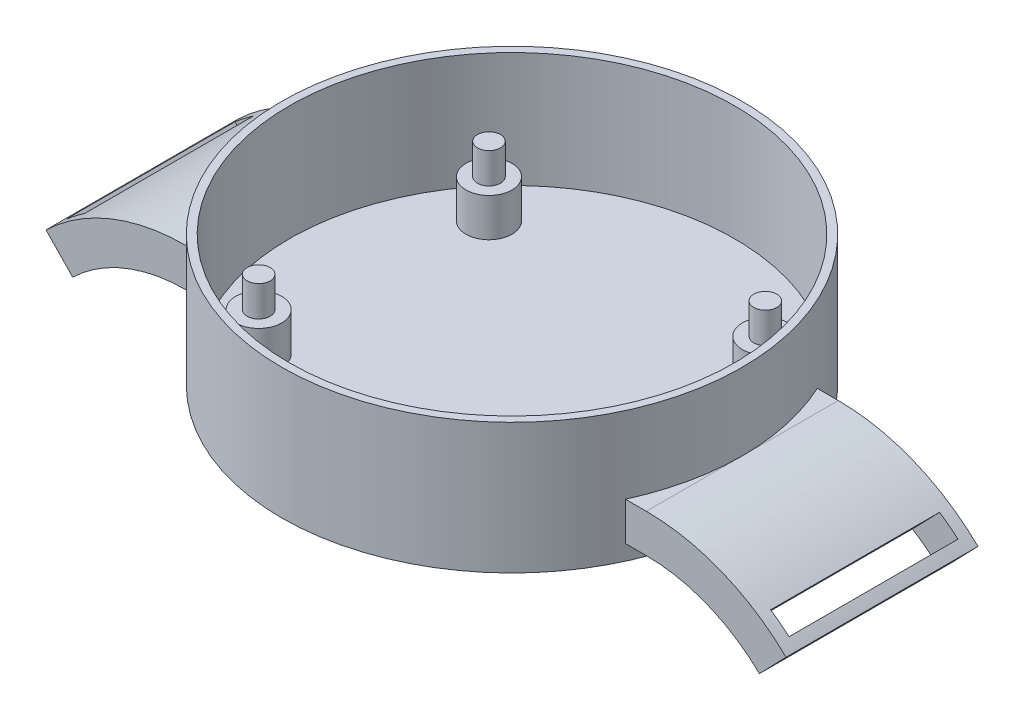
from build123d import *

# Parameters (mm, degrees)
SKETCH1_R                = 30
BOSS_EXTRUDE1_DEPTH      = 17
SKETCH2_R                = 29
CUT_EXTRUDE1_DEPTH       = 15
SKETCH3_R                = 3
BOSS_EXTRUDE5_DEPTH      = 5
SKETCH4_R                = 1.5
BOSS_EXTRUDE6_DEPTH      = 4
BOSS_EXTRUDE7_REACH      = 71.203
BOSS_EXTRUDE7_END_RADIUS = 30
SKETCH6_W                = 25
SKETCH6_H                = 5
SKETCH9_W                = 25
SKETCH9_H                = 5
SKETCH10_W               = 3
SKETCH10_H               = 22
CUT_EXTRUDE2_DEPTH       = 10
CIRPATTERN1_COUNT        = 2


with BuildPart() as part:
    # Sketch1 → Boss-Extrude1 (new body)
    with BuildSketch(Plane(origin=(0, 0, 0), x_dir=(1, 0, 0), z_dir=(0, 1, 0))):
        with Locations(Location((0, 0, 0), (0, 0, 270))):
            Circle(SKETCH1_R)
    extrude(amount=BOSS_EXTRUDE1_DEPTH)

    # Sketch2 → Cut-Extrude1 (cut)
    with BuildSketch(Plane(origin=(0, 17, 0), x_dir=(1, 0, 0), z_dir=(0, 1, 0))):
        with Locations(Location((0, 0, 0), (0, 0, 270))):
            Circle(SKETCH2_R)
    extrude(amount=-CUT_EXTRUDE1_DEPTH, mode=Mode.SUBTRACT)

    # Sketch3 → Boss-Extrude5 (add)
    with BuildSketch(Plane(origin=(0, 2, 0), x_dir=(1, 0, 0), z_dir=(0, 1, 0))):
        with Locations(Location((-18, 15, 0), (0, 0, 270))):
            Circle(SKETCH3_R)
        with Locations(Location((-18, -15, 0), (0, 0, 270))):
            Circle(SKETCH3_R)
        with Locations(Location((18, -15, 0), (0, 0, 270))):
            Circle(SKETCH3_R)
        with Locations(Location((18, 15, 0), (0, 0, 270))):
            Circle(SKETCH3_R)
    extrude(amount=BOSS_EXTRUDE5_DEPTH)

    # Sketch4 → Boss-Extrude6 (add)
    with BuildSketch(Plane(origin=(0, 7, 0), x_dir=(1, 0, 0), z_dir=(0, 1, 0))):
        with Locations(Location((-18, 15, 0), (0, 0, 270))):
            Circle(SKETCH4_R)
        with Locations(Location((-18, -15, 0), (0, 0, 270))):
            Circle(SKETCH4_R)
        with Locations(Location((18, 15, 0), (0, 0, 270))):
            Circle(SKETCH4_R)
        with Locations(Location((18, -15, 0), (0, 0, 270))):
            Circle(SKETCH4_R)
    extrude(amount=BOSS_EXTRUDE6_DEPTH)

    # Boss-Extrude7: up to this cylinder (the profile starts outside it)
    boss_extrude7_end = Plane(origin=(0, 4.5, 0), z_dir=(0, -1, 0)) * Cylinder(BOSS_EXTRUDE7_END_RADIUS, 203.406, mode=Mode.PRIVATE)
    # Sketch6 → Boss-Extrude7 (add, up to the surface)
    with BuildSketch(Plane.ZY.offset(30), mode=Mode.PRIVATE) as boss_extrude7_sk1:
        with Locations((0, 4.5)):
            Rectangle(SKETCH6_W, SKETCH6_H)
    boss_extrude7_tool1 = extrude(boss_extrude7_sk1.sketch, amount=-BOSS_EXTRUDE7_REACH, mode=Mode.PRIVATE) - boss_extrude7_end
    boss_extrude7 = boss_extrude7_tool1.solids().sort_by_distance((-30, 4.5, 0))[0] + boss_extrude7_tool1.solids().sort_by_distance((-30, 4.5, 0))[1]
    add(boss_extrude7)

    # Sweep1: sweep along a path in Sketch7
    with BuildLine(Plane.XY) as sweep1_path:
        ThreePointArc((-30, 4.5), (-38.878296183, 2.772912041), (-46.461716328, -2.156460621))
    # Sketch9 → Sweep1 (sweep)
    with BuildSketch(Plane.ZY.offset(30)):
        with Locations((0, 4.5)):
            Rectangle(SKETCH9_W, SKETCH9_H)
    sweep1 = sweep(path=sweep1_path.line)

    # Sketch10 → Cut-Extrude2 (cut)
    with BuildSketch(Plane(origin=(-23.106823791, 23.900351253, 0), x_dir=(0.7189410106609229, 0.6950710921839945, 0), z_dir=(-0.6950710921839945, 0.7189410106609229, 0))):
        with Locations((-31.902126733, 0)):
            Rectangle(SKETCH10_W, SKETCH10_H)
    cut_extrude2 = extrude(amount=-CUT_EXTRUDE2_DEPTH, mode=Mode.SUBTRACT)

    # CirPattern1: Boss-Extrude7, Sweep1, Cut-Extrude2 ×2 about axis
    cirpattern1_axis = Axis((0, 0, 0), (0, 1, 0))
    add([boss_extrude7.rotate(cirpattern1_axis, i * 360 / CIRPATTERN1_COUNT) for i in range(1, CIRPATTERN1_COUNT)])
    add([sweep1.rotate(cirpattern1_axis, i * 360 / CIRPATTERN1_COUNT) for i in range(1, CIRPATTERN1_COUNT)])
    add([cut_extrude2.rotate(cirpattern1_axis, i * 360 / CIRPATTERN1_COUNT) for i in range(1, CIRPATTERN1_COUNT)], mode=Mode.SUBTRACT)


solid = part.part
